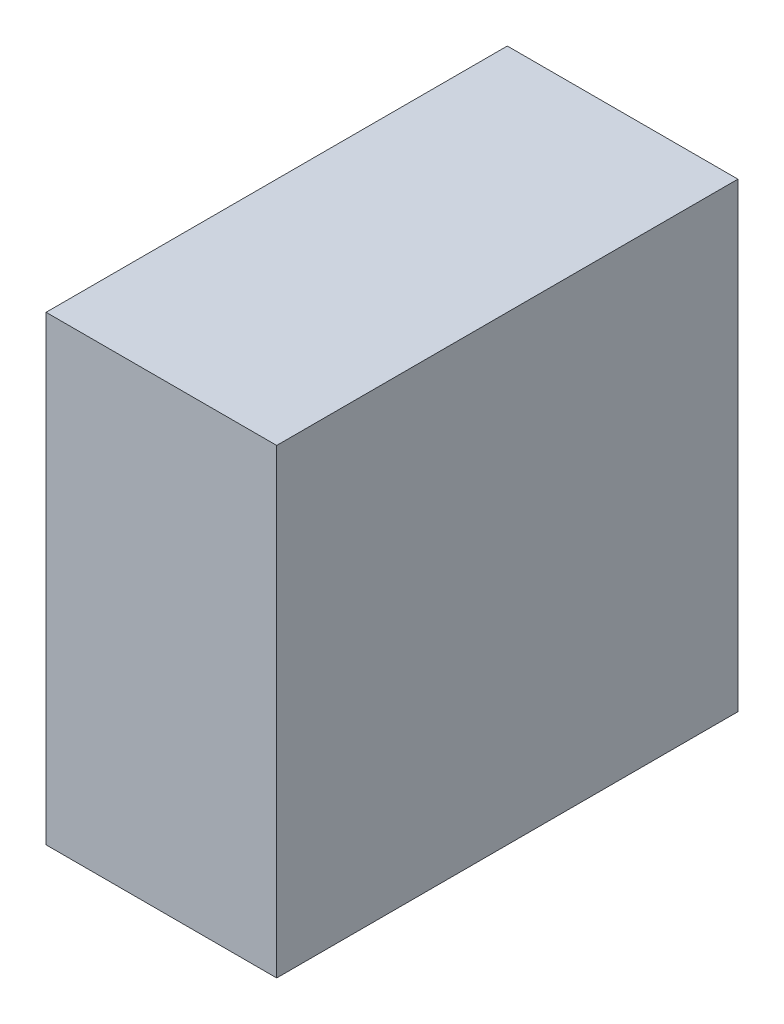
from build123d import *

# Parameters (mm, degrees)
SKETCH1_W           = 40
SKETCH1_H           = 40
BOSS_EXTRUDE1_DEPTH = 40
CUT_EXTRUDE1_DEPTH  = 40
SKETCH3_W           = 20
SKETCH3_H           = 20
CUT_EXTRUDE2_DEPTH  = 40
CUT_EXTRUDE3_DEPTH  = 40


with BuildPart() as part:
    # Sketch1 → Boss-Extrude1 (new body)
    with BuildSketch(Plane.XY):
        with Locations((20, 20)):
            Rectangle(SKETCH1_W, SKETCH1_H)
    extrude(amount=BOSS_EXTRUDE1_DEPTH)

    # Sketch2 → Cut-Extrude1 (cut)
    with BuildSketch(Plane.XY.offset(40)):
        Polygon((0, 0), (20, 40), (0, 40), align=None)
    extrude(amount=-CUT_EXTRUDE1_DEPTH, mode=Mode.SUBTRACT)

    # Sketch3 → Cut-Extrude2 (cut)
    with BuildSketch(Plane(origin=(0, 0, 0), x_dir=(-1, 0, 0), z_dir=(0, -1, 0))):
        with Locations((-10, -30)):
            Rectangle(SKETCH3_W, SKETCH3_H)
    extrude(amount=-CUT_EXTRUDE2_DEPTH, mode=Mode.SUBTRACT)

    # Sketch4 → Cut-Extrude3 (cut)
    with BuildSketch(Plane.XZ):
        Polygon((20, 0), (0, 20), (0, 0), align=None)
    extrude(amount=-CUT_EXTRUDE3_DEPTH, mode=Mode.SUBTRACT)


solid = part.part
